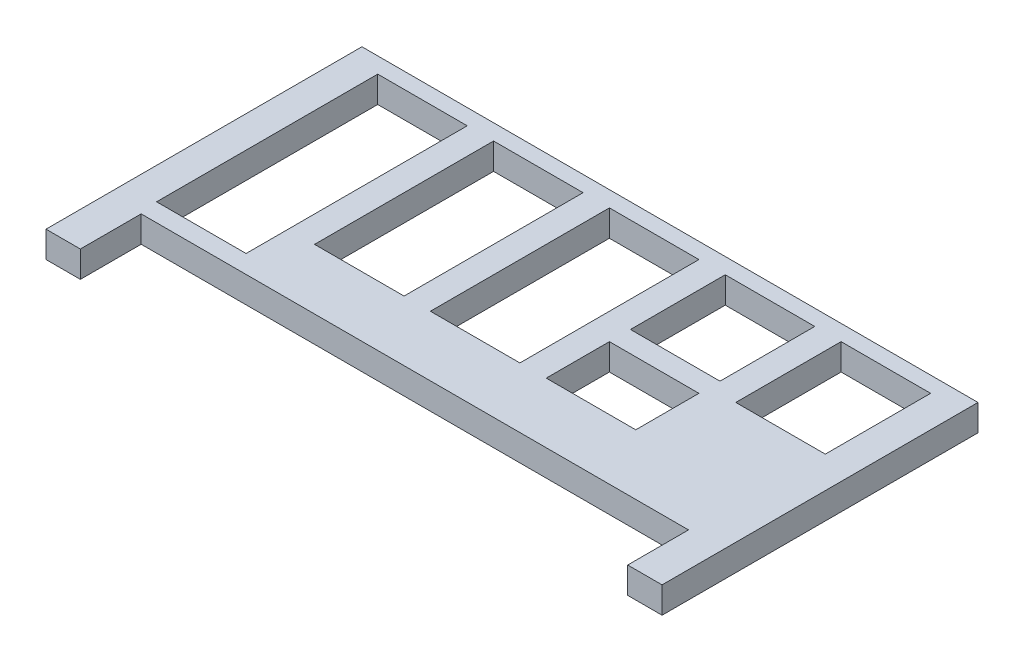
from build123d import *

# Parameters (mm, degrees)
SKETCH1_W           = 17
SKETCH1_H           = 12
SKETCH1_H_2         = 42
SKETCH1_H_3         = 34
SKETCH1_H_4         = 18
SKETCH1_H_5         = 20
BOSS_EXTRUDE1_DEPTH = 5


with BuildPart() as part:
    # Sketch1 → Boss-Extrude1 (new body)
    with BuildSketch(Plane(origin=(0, 0, 0), x_dir=(1, 0, 0), z_dir=(0, 1, 0))):
        Polygon((-58.5, 30), (-58.5, -30), (-51.975, -30), (-51.975, -18.45), (51.975, -18.45), (51.975, -30), (58.5, -30), (58.5, 30), align=None)
        with Locations((22, -1)):
            Rectangle(SKETCH1_W, SKETCH1_H, mode=Mode.SUBTRACT)
        with Locations((-44, 6)):
            Rectangle(SKETCH1_W, SKETCH1_H_2, mode=Mode.SUBTRACT)
        with Locations((-22, 10)):
            Rectangle(SKETCH1_W, SKETCH1_H_3, mode=Mode.SUBTRACT)
        with Locations((0, 10)):
            Rectangle(SKETCH1_W, SKETCH1_H_3, mode=Mode.SUBTRACT)
        with Locations((22, 18)):
            Rectangle(SKETCH1_W, SKETCH1_H_4, mode=Mode.SUBTRACT)
        with Locations((44, 17)):
            Rectangle(SKETCH1_W, SKETCH1_H_5, mode=Mode.SUBTRACT)
    extrude(amount=BOSS_EXTRUDE1_DEPTH)


solid = part.part
